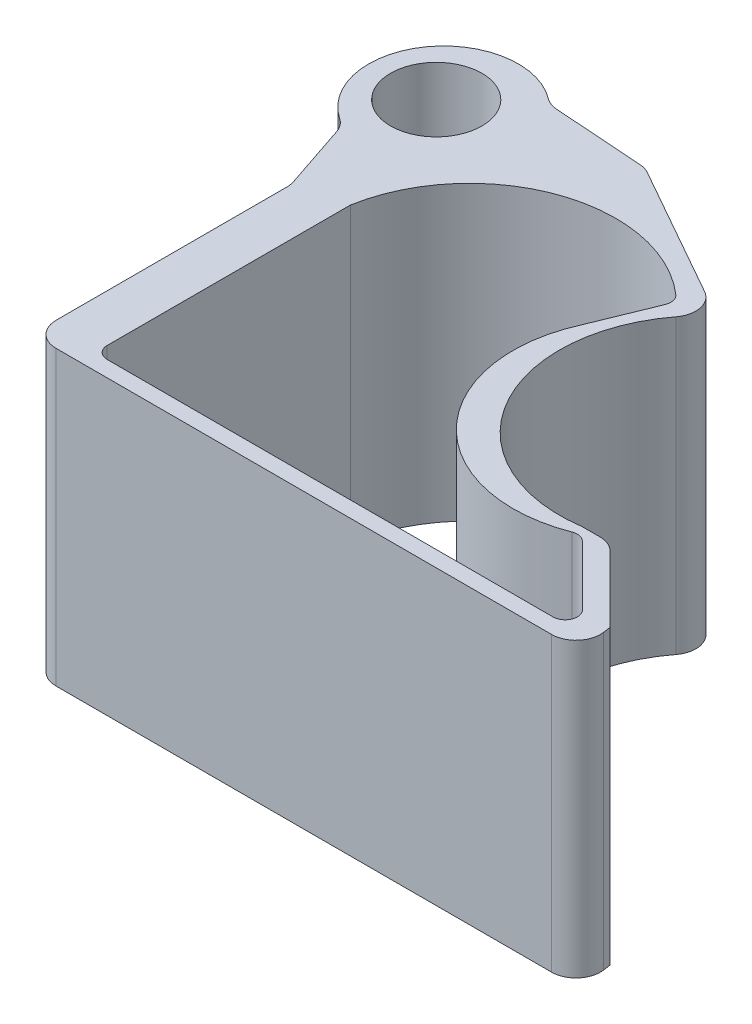
from build123d import *

# Parameters (mm, degrees)
SKETCH1_R           = 4.7625
BOSS_EXTRUDE2_DEPTH = 30.48
FILLET1_R           = 2.54


with BuildPart() as part:
    # Sketch1 → Boss-Extrude2 (new body)
    with BuildSketch(Plane(origin=(0, 0, 0), x_dir=(1, 0, 0), z_dir=(0, 1, 0))):
        with BuildLine():
            Line((45.005946436, 2.027668921), (45.515150945, -1.656575462))
            Line((45.515150945, -1.656575462), (-11.575660389, -1.656575462))
            Line((-11.575660389, -1.656575462), (-11.575660389, 25.36121668))
            Line((-11.575660389, 25.36121668), (-14.280396301, 33.422664026))
            ThreePointArc((-14.280396301, 33.422664026), (-17.000257473, 44.802695642), (-5.367910813, 46.064153357))
            Line((-5.367910813, 46.064153357), (5.377854414, 45.31005212))
            Line((5.377854414, 45.31005212), (22.451182043, 35.66511967))
            ThreePointArc((22.451182043, 35.66511967), (18.704388059, 18.178130753), (34.432464589, 9.665736544))
            Line((34.432464589, 9.665736544), (37.367878813, 9.665736544))
            Line((37.367878813, 9.665736544), (45.005946436, 2.027668921))
        make_face()
        with Locations((-11.678835755, 40.598351677)):
            Circle(SKETCH1_R, mode=Mode.SUBTRACT)
        with BuildLine():
            Line((16.202668925, 27.801375987), (18.746230839, 34.046195278))
            ThreePointArc((18.746230839, 34.046195278), (18.80575079, 34.818433424), (18.405670977, 35.481630621))
            ThreePointArc((18.405670977, 35.481630621), (3.288167743, 38.370043483), (-6.637910813, 26.607611872))
            Line((-6.637910813, 26.607611872), (-6.637910813, 1.27))
            ThreePointArc((-6.637910813, 1.27), (-6.265936425, 0.371974388), (-5.367910813, 0))
            Line((-5.367910813, 0), (41.091115974, 0))
            ThreePointArc((41.091115974, 0), (42.264718256, 0.784657148), (41.988123028, 2.169043017))
            Line((41.988123028, 2.169043017), (35.775365429, 8.367731265))
            ThreePointArc((35.775365429, 8.367731265), (35.139277633, 8.711596588), (34.418608086, 8.652550432))
            ThreePointArc((34.418608086, 8.652550432), (18.894618686, 12.123517004), (16.202668925, 27.801375987))
        make_face(mode=Mode.SUBTRACT)
    extrude(amount=BOSS_EXTRUDE2_DEPTH)

    # Fillet1
    fillet1_edges = [part.edges().sort_by_distance(p)[0] for p in [
        (45.515150945, 15.24, 1.656575462),
        (-11.575660389, 15.24, 1.656575462),
        (-11.575660389, 15.24, -25.36121668),
        (-14.280396301, 15.24, -33.422664026),
        (-5.367910813, 15.24, -46.064153357),
        (5.377854414, 15.24, -45.31005212),
        (22.451182043, 15.24, -35.66511967),
        (37.367878813, 15.24, -9.665736544),
    ]]
    fillet(fillet1_edges, radius=FILLET1_R)


solid = part.part
